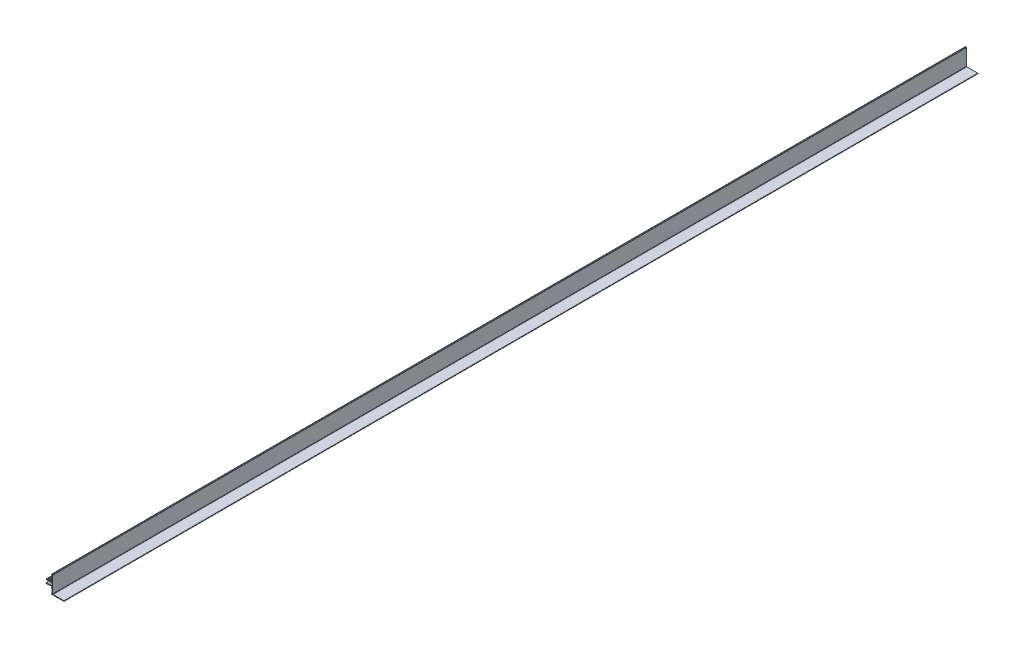
from build123d import *

# Parameters (mm, degrees)
MAIN_EXTRUSION_DEPTH = 2000


with BuildPart() as part:
    # Sk Main Extrusion → Main Extrusion (new body)
    with BuildSketch(Plane.XY):
        with BuildLine():
            Line((-3.829999995, 2.532800268), (-11.312491547, 2.92508363))
            ThreePointArc((-11.312491547, 2.92508363), (-11.819968112, 3.366238977), (-11.514692349, 3.965369358))
            Line((-11.514692349, 3.965369358), (-10.100108722, 4.625000536))
            Line((-10.100108722, 4.625000536), (-9.58, 4.300000536))
            Line((-9.58, 4.300000536), (-8.08, 4.300000536))
            Line((-8.08, 4.300000536), (-5.474147193, 5.000000536))
            Line((-5.474147193, 5.000000536), (-4.934147193, 5.000000536))
            Line((-4.934147193, 5.000000536), (-4.23, 4.56))
            Line((-4.23, 4.56), (-4.23, 4.025000268))
            ThreePointArc((-4.23, 4.025000268), (-4.112842712, 3.742157556), (-3.83, 3.625000268))
            Line((-3.83, 3.625000268), (1.67, 3.625000268))
            Line((1.67, 3.625000268), (1.67, 5.120055436))
            Line((1.67, 5.120055436), (1.19886836, 5.120055436))
            ThreePointArc((1.19886836, 5.120055436), (0.3740485, 5.504367422), (0.038, 6.350000268))
            Line((0.038, 6.350000268), (0.038, 6.650000268))
            ThreePointArc((0.038, 6.650000268), (0.3740485, 7.495633114), (1.19886836, 7.8799451))
            Line((1.19886836, 7.8799451), (1.67, 7.8799451))
            Line((1.67, 7.8799451), (1.67, 17.050000268))
            ThreePointArc((1.67, 17.050000268), (1.450330086, 17.580330354), (0.92, 17.800000268))
            Line((0.92, 17.800000268), (0.663, 17.800000268))
            ThreePointArc((0.663, 17.800000268), (0.038, 18.425000268), (0.663, 19.050000268))
            Line((0.663, 19.050000268), (2.17, 19.050000268))
            ThreePointArc((2.17, 19.050000268), (2.700330086, 18.830330354), (2.92, 18.300000268))
            Line((2.92, 18.300000268), (2.92, -17.049999732))
            ThreePointArc((2.92, -17.049999732), (3.139669914, -17.580329818), (3.67, -17.799999732))
            Line((3.67, -17.799999732), (27.295, -17.799999732))
            ThreePointArc((27.295, -17.799999732), (27.92, -18.424999732), (27.295, -19.049999732))
            Line((27.295, -19.049999732), (0.663, -19.049999732))
            ThreePointArc((0.663, -19.049999732), (0.038, -18.424999732), (0.663, -17.799999732))
            Line((0.663, -17.799999732), (0.92, -17.799999732))
            ThreePointArc((0.92, -17.799999732), (1.450330086, -17.580329818), (1.67, -17.049999732))
            Line((1.67, -17.049999732), (1.67, -7.879944832))
            Line((1.67, -7.879944832), (1.19886836, -7.879944832))
            ThreePointArc((1.19886836, -7.879944832), (0.3740485, -7.495632846), (0.038, -6.65))
            Line((0.038, -6.65), (0.038, -6.35))
            ThreePointArc((0.038, -6.35), (0.3740485, -5.504367154), (1.19886836, -5.120055168))
            Line((1.19886836, -5.120055168), (1.67, -5.120055168))
            Line((1.67, -5.120055168), (1.67, -3.625))
            Line((1.67, -3.625), (-3.83, -3.625))
            ThreePointArc((-3.83, -3.625), (-4.112842712, -3.742157288), (-4.23, -4.025))
            Line((-4.23, -4.025), (-4.23, -4.56))
            Line((-4.23, -4.56), (-4.934147193, -5))
            Line((-4.934147193, -5), (-5.474147193, -5))
            Line((-5.474147193, -5), (-8.08, -4.3))
            Line((-8.08, -4.3), (-9.58, -4.3))
            Line((-9.58, -4.3), (-10.100108722, -4.625))
            Line((-10.100108722, -4.625), (-11.51469235, -3.965368821))
            ThreePointArc((-11.51469235, -3.965368821), (-11.819968112, -3.36623844), (-11.312491547, -2.925083093))
            Line((-11.312491547, -2.925083093), (-3.830000005, -2.532799732))
            Line((-3.830000005, -2.532799732), (1.67, -2.436796875))
            Line((1.67, -2.436796875), (1.67, 2.436797411))
            Line((1.67, 2.436797411), (-3.829999995, 2.532800268))
        make_face()
    extrude(amount=-MAIN_EXTRUSION_DEPTH)


solid = part.part
